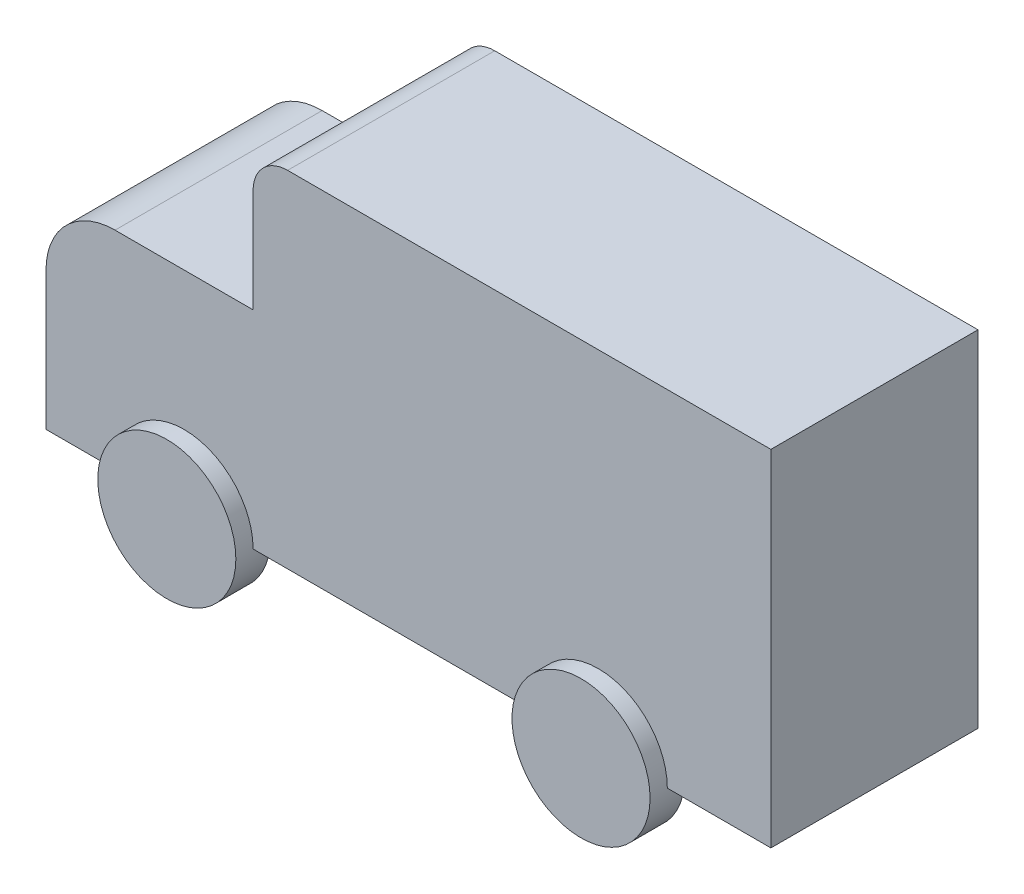
from build123d import *

# Parameters (mm, degrees)
EXTRUDE_1_DEPTH = 600
EXTRUDE_START   = 600
SKETCH_1_3_R    = 400
EXTRUDE_2_DEPTH = 100


with BuildPart() as part:
    # 스케치1 → 보스-돌출1 (new, symmetric)
    with BuildSketch(Plane.XY):
        with BuildLine():
            Line((1500, -1000), (1500, 1000))
            Line((1500, 1000), (-1300, 1000))
            ThreePointArc((-1300, 1000), (-1441.421356237, 941.421356237), (-1500, 800))
            Line((-1500, 800), (-1500, 200))
            Line((-1500, 200), (-2300, 200))
            ThreePointArc((-2300, 200), (-2582.842712475, 82.842712475), (-2700, -200))
            Line((-2700, -200), (-2700, -1000))
            Line((-2700, -1000), (1500, -1000))
        make_face()
    extrude(amount=EXTRUDE_1_DEPTH, both=True)

    # 스케치1<3> → 보스-돌출2 (add, symmetric)
    with BuildSketch(Plane.XY.offset(EXTRUDE_START)):
        with Locations((500, -1000)):
            Circle(SKETCH_1_3_R)
        with Locations((-1900, -1000)):
            Circle(SKETCH_1_3_R)
    extrude_2 = extrude(amount=EXTRUDE_2_DEPTH, both=True)

    # 대칭 복사1: 보스-돌출2 across plane
    add(extrude_2.mirror(Plane.XY))


solid = part.part
